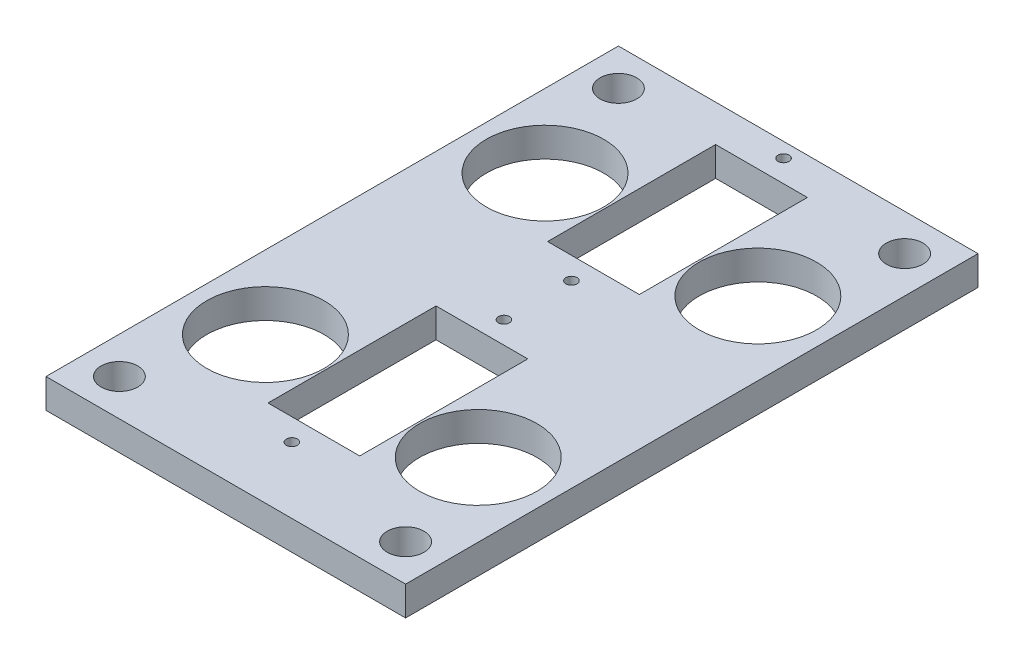
from build123d import *

# Parameters (mm, degrees)
CROQUIS1_W              = 49
CROQUIS1_H              = 73
CROQUIS1_R              = 8
CROQUIS1_R_2            = 2.5
CROQUIS1_W_2            = 12.5
CROQUIS1_H_2            = 22.9
SALIENTE_EXTRUIR4_DEPTH = 4
CROQUIS5_R              = 0.75
CORTAR_EXTRUIR1_DEPTH   = 4
CROQUIS7_W              = 49
CROQUIS7_H              = 5
SALIENTE_EXTRUIR5_DEPTH = 4
CROQUIS8_R              = 2.5
CORTAR_EXTRUIR2_DEPTH   = 10


with BuildPart() as part:
    # Croquis1 → Saliente-Extruir4 (new body)
    with BuildSketch(Plane(origin=(0, 0, 0), x_dir=(1, 0, 0), z_dir=(0, 1, 0))):
        with Locations((0, 0.5)):
            Rectangle(CROQUIS1_W, CROQUIS1_H)
        with Locations((14.5, -21.1)):
            Circle(CROQUIS1_R, mode=Mode.SUBTRACT)
        with Locations((-14.5, -21.1)):
            Circle(CROQUIS1_R, mode=Mode.SUBTRACT)
        with Locations((-14.5, 17)):
            Circle(CROQUIS1_R, mode=Mode.SUBTRACT)
        with Locations((14.5, 17)):
            Circle(CROQUIS1_R, mode=Mode.SUBTRACT)
        with Locations((-19.5, 32)):
            Circle(CROQUIS1_R_2, mode=Mode.SUBTRACT)
        with Locations((19.5, 32)):
            Circle(CROQUIS1_R_2, mode=Mode.SUBTRACT)
        with Locations((0, -17.55)):
            Rectangle(CROQUIS1_W_2, CROQUIS1_H_2, mode=Mode.SUBTRACT)
        with Locations((0, 20.55)):
            Rectangle(CROQUIS1_W_2, CROQUIS1_H_2, mode=Mode.SUBTRACT)
    extrude(amount=SALIENTE_EXTRUIR4_DEPTH)

    # Croquis5 → Cortar-Extruir1 (cut)
    with BuildSketch(Plane(origin=(0, 4, 0), x_dir=(1, 0, 0), z_dir=(0, 1, 0))):
        with Locations((0, 35)):
            Circle(CROQUIS5_R)
        with Locations((0, 6.1)):
            Circle(CROQUIS5_R)
        with Locations((0, -3.1)):
            Circle(CROQUIS5_R)
        with Locations((0, -32)):
            Circle(CROQUIS5_R)
    extrude(amount=-CORTAR_EXTRUIR1_DEPTH, mode=Mode.SUBTRACT)

    # Croquis7 → Saliente-Extruir5 (add)
    with BuildSketch(Plane(origin=(0, 4, 0), x_dir=(1, 0, 0), z_dir=(0, 1, 0))):
        with Locations((0, -38.5)):
            Rectangle(CROQUIS7_W, CROQUIS7_H)
    extrude(amount=-SALIENTE_EXTRUIR5_DEPTH)

    # Croquis8 → Cortar-Extruir2 (cut)
    with BuildSketch(Plane(origin=(0, 4, 0), x_dir=(1, 0, 0), z_dir=(0, 1, 0))):
        with Locations((-19.5, -36)):
            Circle(CROQUIS8_R)
        with Locations((19.5, -36)):
            Circle(CROQUIS8_R)
    extrude(amount=-CORTAR_EXTRUIR2_DEPTH, mode=Mode.SUBTRACT)


solid = part.part
